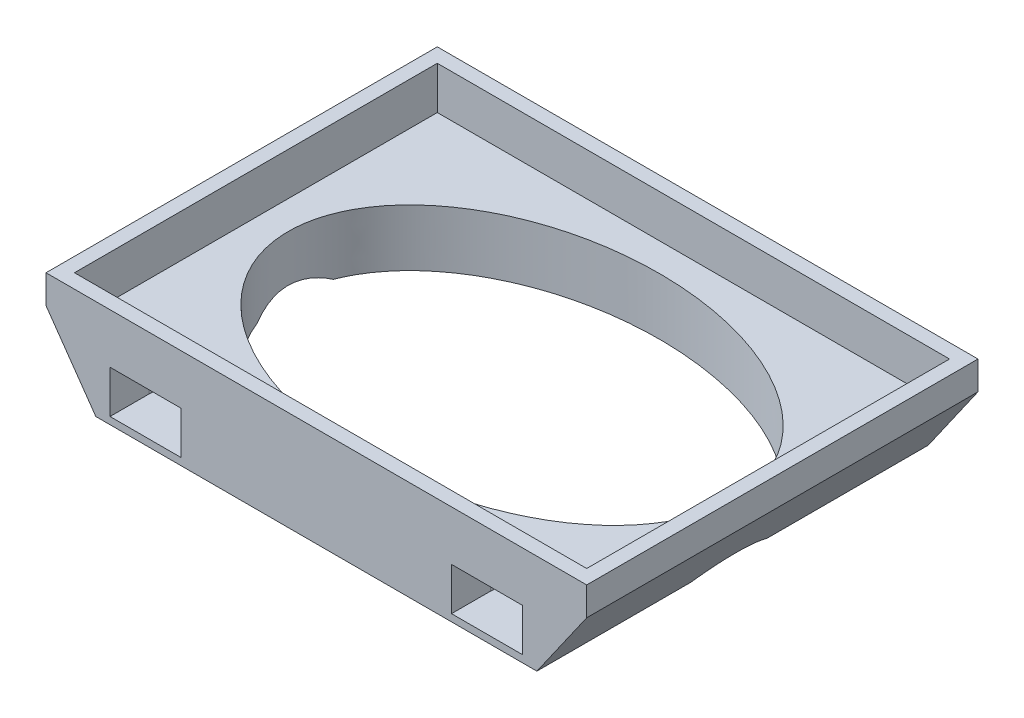
from build123d import *

# Parameters (mm, degrees)
SKETCH1_W               = 38
SKETCH1_H               = 27.5
BOSS_EXTRUDE1_DEPTH     = 7
SKETCH2_W               = 36
SKETCH2_H               = 25.5
CUT_EXTRUDE1_DEPTH      = 3
CUT_EXTRUDE2_DEPTH      = 24.792068006
CUT_EXTRUDE2_DEPTH_BACK = 24.792068006
SKETCH3_RX              = 16.007748615
SKETCH3_RY              = 10.755206101
CUT_EXTRUDE4_DEPTH      = 1.5
CUT_EXTRUDE5_DEPTH      = 25.475753471
CUT_EXTRUDE5_DEPTH_BACK = 25.475753471


with BuildPart() as part:
    # Sketch1 → Boss-Extrude1 (new body)
    with BuildSketch(Plane(origin=(0, 0, 0), x_dir=(1, 0, 0), z_dir=(0, 1, 0))):
        Rectangle(SKETCH1_W, SKETCH1_H)
    extrude(amount=-BOSS_EXTRUDE1_DEPTH)

    # Sketch2 → Cut-Extrude1 (cut)
    with BuildSketch(Plane(origin=(0, 0, 0), x_dir=(1, 0, 0), z_dir=(0, 1, 0))):
        Rectangle(SKETCH2_W, SKETCH2_H)
    extrude(amount=-CUT_EXTRUDE1_DEPTH, mode=Mode.SUBTRACT)

    # Sketch3 → Cut-Extrude2 (cut, two sides: drawn at the far end of the back side and taken through both)
    with BuildSketch(Plane(origin=(0, -3, 0), x_dir=(1, 0, 0), z_dir=(0, 1, 0)).offset(-CUT_EXTRUDE2_DEPTH_BACK)):
        with Locations(Location((0, 0), (0, 0, -1.782797699))):
            Ellipse(SKETCH3_RX, SKETCH3_RY)
    extrude(amount=CUT_EXTRUDE2_DEPTH + CUT_EXTRUDE2_DEPTH_BACK, mode=Mode.SUBTRACT)

    # Sketch8 → Cut-Extrude4 (cut, symmetric)
    with BuildSketch(Plane(origin=(0, -5, 0), x_dir=(-1, 0, 0), z_dir=(0, -1, 0))):
        with BuildLine():
            Line((-14.5, 11), (-14.5, 23.562662058))
            Line((-14.5, 23.562662058), (-9.5, 23.562662058))
            Line((-9.5, 23.562662058), (-9.5, 11))
            ThreePointArc((-9.5, 11), (-12, 8.5), (-14.5, 11))
        make_face()
        with BuildLine():
            Line((9.5, 23.562662058), (9.5, 11))
            ThreePointArc((9.5, 11), (12, 8.5), (14.5, 11))
            Line((14.5, 11), (14.5, 23.562662058))
            Line((14.5, 23.562662058), (9.5, 23.562662058))
        make_face()
        with BuildLine():
            Line((14.5, -11), (14.5, -23.562662058))
            Line((14.5, -23.562662058), (9.5, -23.562662058))
            Line((9.5, -23.562662058), (9.5, -11))
            ThreePointArc((9.5, -11), (12, -8.5), (14.5, -11))
        make_face()
        with BuildLine():
            Line((-9.5, -23.562662058), (-9.5, -11))
            ThreePointArc((-9.5, -11), (-12, -8.5), (-14.5, -11))
            Line((-14.5, -11), (-14.5, -23.562662058))
            Line((-14.5, -23.562662058), (-9.5, -23.562662058))
        make_face()
    extrude(amount=CUT_EXTRUDE4_DEPTH, both=True, mode=Mode.SUBTRACT)

    # Sketch9 → Cut-Extrude5 (cut, two sides: drawn at the far end of the back side and taken through both)
    with BuildSketch(Plane.XY.offset(-CUT_EXTRUDE5_DEPTH_BACK)):
        Polygon((-15.498962309, -7), (-19, -2), (-19, -7), align=None)
        Polygon((19, -7), (15.498962309, -7), (19, -2), align=None)
    extrude(amount=CUT_EXTRUDE5_DEPTH + CUT_EXTRUDE5_DEPTH_BACK, mode=Mode.SUBTRACT)


solid = part.part
